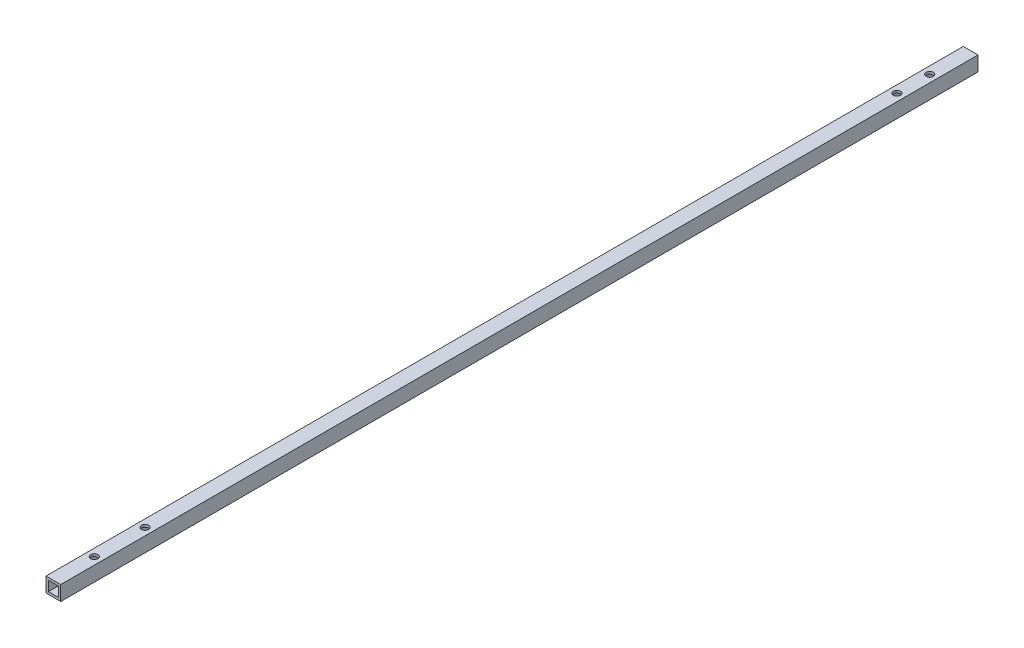
from build123d import *

# Parameters (mm, degrees)
SKETCH_1_W          = 9
SKETCH_1_H          = 9
EXTRUDE_1_DEPTH     = 560.3
SKETCH_2_W          = 6
SKETCH_2_H          = 6
CUT_EXTRUDE_1_DEPTH = 560.3
SKETCH_3_R          = 2.2
CUT_EXTRUDE_2_DEPTH = 582
SKETCH_4_R          = 2.2
CUT_EXTRUDE_3_DEPTH = 20


with BuildPart() as part:
    # ｽｹｯﾁ1 → ﾎﾞｽ - 押し出し1 (new body)
    with BuildSketch(Plane.XY):
        Rectangle(SKETCH_1_W, SKETCH_1_H)
    extrude(amount=EXTRUDE_1_DEPTH)

    # ｽｹｯﾁ2 → ｶｯﾄ - 押し出し1 (cut)
    with BuildSketch(Plane.XY.offset(560.3)):
        Rectangle(SKETCH_2_W, SKETCH_2_H)
    extrude(amount=-CUT_EXTRUDE_1_DEPTH, mode=Mode.SUBTRACT)

    # ｽｹｯﾁ3 → ｶｯﾄ - 押し出し2 (cut)
    with BuildSketch(Plane(origin=(0, 4.5, 0), x_dir=(1, 0, 0), z_dir=(0, 1, 0))):
        with Locations((0, -25)):
            Circle(SKETCH_3_R)
        with Locations((0, -45)):
            Circle(SKETCH_3_R)
    extrude(amount=-CUT_EXTRUDE_2_DEPTH, mode=Mode.SUBTRACT)

    # ｽｹｯﾁ4 → ｶｯﾄ - 押し出し3 (cut)
    with BuildSketch(Plane(origin=(0, 4.5, 0), x_dir=(1, 0, 0), z_dir=(0, 1, 0))):
        with Locations((0, -535.3)):
            Circle(SKETCH_4_R)
        with Locations((0, -504.3)):
            Circle(SKETCH_4_R)
    extrude(amount=-CUT_EXTRUDE_3_DEPTH, mode=Mode.SUBTRACT)


solid = part.part
